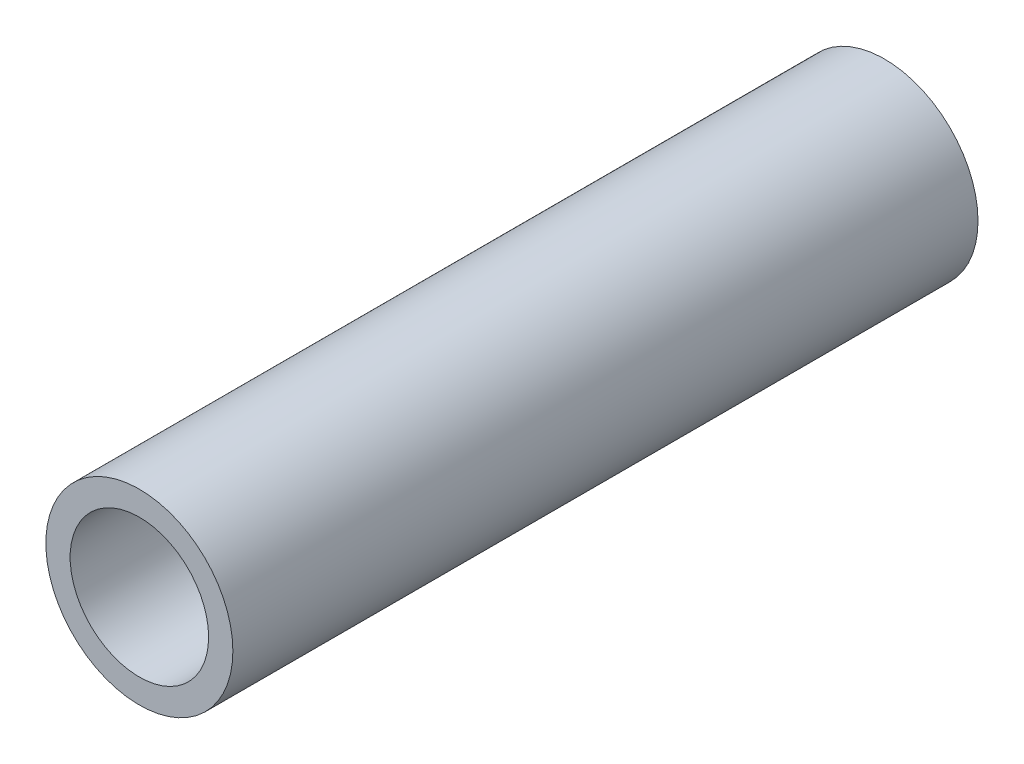
from build123d import *

# Parameters (mm, degrees)
SKETCH1_R           = 10.668
SKETCH1_R_2         = 7.8994
EXTRUDE_THIN1_DEPTH = 42.5


with BuildPart() as part:
    # Sketch1 → Extrude-Thin1 (new body, symmetric)
    with BuildSketch(Plane.XY):
        Circle(SKETCH1_R)
        Circle(SKETCH1_R_2, mode=Mode.SUBTRACT)
    extrude(amount=EXTRUDE_THIN1_DEPTH, both=True)


solid = part.part
